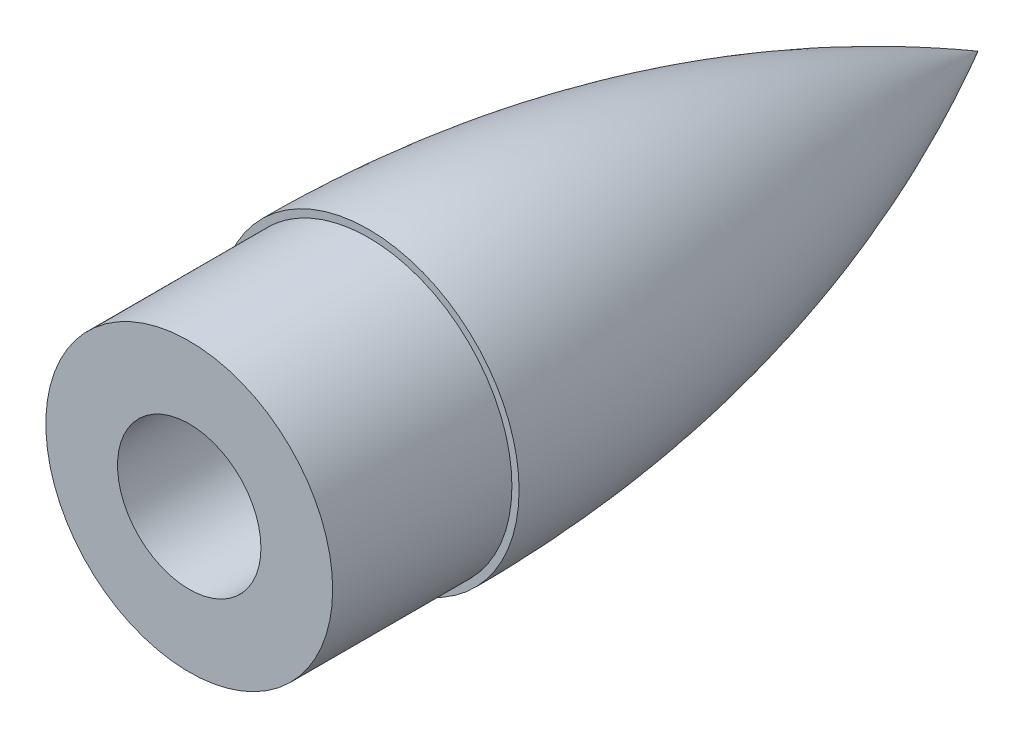
from build123d import *

# Parameters (mm, degrees)
SKETCH18_W          = 20
SKETCH18_H          = 12
BOSS_EXTRUDE2_DEPTH = 10
SKETCH19_R          = 1.5
CUT_EXTRUDE1_DEPTH  = 15
SWEEP2_PROFILE_R    = 5
SKETCH46_R          = 40
BOSS_EXTRUDE4_DEPTH = 50
CUT_EXTRUDE3_START  = -80
SKETCH47_R          = 20
CUT_EXTRUDE3_DEPTH  = 80


with BuildPart() as part:
    # Sketch1 → Revolve6 (revolve)
    with BuildSketch(Plane(origin=(0, 0, 0), x_dir=(0, 0, -1), z_dir=(1, 0, 0))):
        with BuildLine():
            Line((0, 40), (0, 42))
            add(Edge.make_bspline(
                [(0, 42), (92.195444573, 42), (170, 0)],
                knots=[0, 0, 0, 1, 1, 1], degree=2))
            Line((170, 0), (168, 0))
            add(Edge.make_bspline(
                [(0, 40), (91.00549434, 40), (168, 0)],
                knots=[0, 0, 0, 1, 1, 1], degree=2))
        make_face()
    revolve(axis=Axis((0, 0, 168), (0, 0, -1)))



with BuildPart() as body_2:
    # Sketch15 → Revolve7 (revolve)
    with BuildSketch(Plane(origin=(0, 0, 0), x_dir=(0, 0, -1), z_dir=(1, 0, 0))):
        with BuildLine():
            Line((0, 40), (0, 0))
            Line((0, 0), (168, 0))
            add(Edge.make_bspline(
                [(0, 40), (91.00549434, 40), (168, 0)],
                knots=[0, 0, 0, 1, 1, 1], degree=2))
        make_face()
    revolve(axis=Axis((0, 0, -168), (0, 0, 1)))

    # Sketch16 → Cut-Revolve1 (revolve, cut)
    with BuildSketch(Plane(origin=(0, 0, 0), x_dir=(0, 0, -1), z_dir=(1, 0, 0))):
        with BuildLine():
            Line((85, 0), (0, 0))
            Line((0, 0), (-9.8e-08, 40))
            add(Edge.make_bspline(
                [(-9.8e-08, 40), (44.148690773, 40.000000011), (85, 30.586298474)],
                knots=[0, 0, 0, 1, 1, 1], degree=2))
            Line((85, 30.586298474), (85, 0))
        make_face()
    revolve(axis=Axis((0, 0, -85), (0, 0, 1)), mode=Mode.SUBTRACT)


with BuildPart() as part_1:
    add(part.part)

    add(body_2.part)  # Boss-Extrude2 merges body 2
    # Sketch18 → Boss-Extrude2 (add)
    with BuildSketch(Plane.XY.offset(-85)):
        with Locations((0, 18)):
            Rectangle(SKETCH18_W, SKETCH18_H)
        with Locations((0, -18)):
            Rectangle(SKETCH18_W, SKETCH18_H)
    extrude(amount=BOSS_EXTRUDE2_DEPTH)

    # Sketch19 → Cut-Extrude1 (cut)
    with BuildSketch(Plane.XY.offset(-75)):
        with Locations((-8, 18)):
            Circle(SKETCH19_R)
        with Locations((8, 18)):
            Circle(SKETCH19_R)
        with Locations((-8, -18)):
            Circle(SKETCH19_R)
        with Locations((8, -18)):
            Circle(SKETCH19_R)
    extrude(amount=-CUT_EXTRUDE1_DEPTH, mode=Mode.SUBTRACT)

    # Sweep2: sweep along a path in Sketch22
    with BuildLine(Plane(origin=(0, 0, 0), x_dir=(0, 0, -1), z_dir=(1, 0, 0))) as sweep2_path:
        ThreePointArc((75, 18), (59.443329598, -7e-09), (75, -18.000000014))
    # Sweep2 profile (on start of the path) → Sweep2 (sweep)
    with BuildSketch(Plane(origin=(0, 18, -75), x_dir=(0, 0.9894527311891559, 0.1448561104762935), z_dir=(0, -0.1448561104762935, 0.9894527311891559))):
        Circle(SWEEP2_PROFILE_R)
    sweep(path=sweep2_path.line)


with BuildPart() as body_2_2:
    # Sketch43 → Revolve8 (revolve)
    with BuildSketch(Plane(origin=(0, 0, 0), x_dir=(0, 0, -1), z_dir=(1, 0, 0))):
        with BuildLine():
            Line((30, 0), (0, 0))
            Line((0, 0), (0, 40))
            add(Edge.make_bspline(
                [(0, 40), (15.195309174, 40), (30, 38.884822889)],
                knots=[0, 0, 0, 1, 1, 1], degree=2))
            Line((30, 38.884822889), (30, 0))
        make_face()
    revolve(axis=Axis((0, 0, -30), (0, 0, 1)))


with BuildPart() as body_3:
    # Sketch46 → Boss-Extrude4 (new body)
    with BuildSketch(Plane.XY):
        Circle(SKETCH46_R)
    extrude(amount=BOSS_EXTRUDE4_DEPTH)


with BuildPart() as cut_extrude3_tool:
    # Sketch47 → Cut-Extrude3 (new body)
    with BuildSketch(Plane.XY.offset(50).offset(CUT_EXTRUDE3_START)):
        Circle(SKETCH47_R)
    extrude(amount=CUT_EXTRUDE3_DEPTH)


with BuildPart() as body_2_2_1:
    add(body_2_2.part)

    # Cut-Extrude3: cut by cut_extrude3_tool
    add(cut_extrude3_tool.part, mode=Mode.SUBTRACT)


with BuildPart() as body_3_1:
    add(body_3.part)

    # Cut-Extrude3: cut by cut_extrude3_tool
    add(cut_extrude3_tool.part, mode=Mode.SUBTRACT)


solid = Compound([part_1.part, body_2_2_1.part, body_3_1.part])
